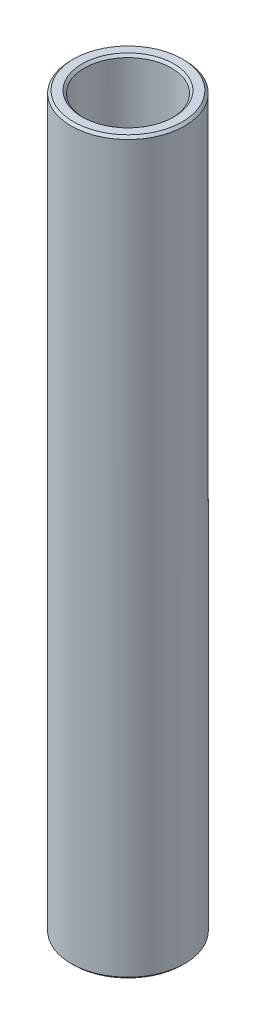
from build123d import *

# Parameters (mm, degrees)
SKETCH1_W     = 0.7
SKETCH1_H     = 38.55
CHAMFER1_SIZE = 0.127


with BuildPart() as part:
    # Sketch1 → Revolve1 (revolve)
    with BuildSketch(Plane.XY):
        with Locations((2.65, 0)):
            Rectangle(SKETCH1_W, SKETCH1_H)
    revolve(axis=Axis((0, 12.831952247, 0), (0, -1, 0)))

    # Chamfer1
    chamfer1_edges = [part.edges().sort_by_distance(p)[0] for p in [
        (-3, 19.275, 0),
        (-3, -19.275, 0),
        (-2.3, -19.275, 0),
        (-2.3, 19.275, 0),
    ]]
    chamfer(chamfer1_edges, length=CHAMFER1_SIZE)


solid = part.part
